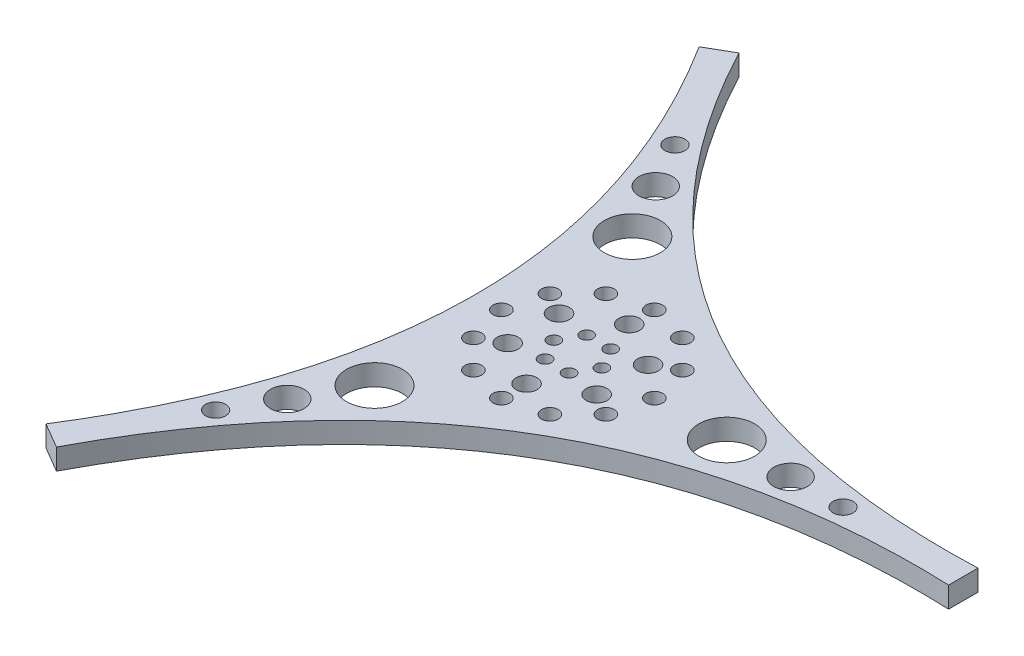
from build123d import *

# Parameters (mm, degrees)
SKETCH_1_R      = 2.392485623
SKETCH_1_R_2    = 4.007871621
SKETCH_1_R_3    = 6.678501703
SKETCH_1_R_4    = 1.5
SKETCH_1_R_5    = 2.5
SKETCH_1_R_6    = 2
EXTRUDE_4_DEPTH = 5


with BuildPart() as part:
    # Эскиз1 → Бобышка-Вытянуть4 (new body)
    with BuildSketch(Plane(origin=(0, 0, 0), x_dir=(1, 0, 0), z_dir=(0, 1, 0))):
        with BuildLine():
            Line((0, 163.036345265), (6.030702091, 166.518172741))
            add(Edge.make_bspline(
                [(6.030702091, 166.518172741), (49.074772944, 85.000000108), (141.146053562, 88.509288197)],
                knots=[0, 0, 0, 1, 1, 1], degree=2))
            Line((141.146053562, 88.509288197), (141.146053562, 81.490712019))
            add(Edge.make_bspline(
                [(6.030701589, 3.481827186), (49.074772944, 85.000000108), (141.146053562, 81.490712019)],
                knots=[0, 0, 0, 1, 1, 1], degree=2))
            Line((6.030701589, 3.481827186), (0, 7.029273997))
            add(Edge.make_bspline(
                [(0, 163.036345265), (49.074772944, 85.000000108), (0, 7.029273997)],
                knots=[0, 0, 0, 1, 1, 1], degree=2))
        make_face()
        with Locations((17.403131543, 139.856892173)):
            Circle(SKETCH_1_R, mode=Mode.SUBTRACT)
        with Locations((23.665499069, 129.010153442)):
            Circle(SKETCH_1_R_2, mode=Mode.SUBTRACT)
        with Locations((31.292672593, 115.79950138)):
            Circle(SKETCH_1_R_3, mode=Mode.SUBTRACT)
        with Locations((112.418055745, 85.000000108)):
            Circle(SKETCH_1_R, mode=Mode.SUBTRACT)
        with Locations((99.893320693, 85.000000108)):
            Circle(SKETCH_1_R_2, mode=Mode.SUBTRACT)
        with Locations((84.638973644, 85.000000108)):
            Circle(SKETCH_1_R_3, mode=Mode.SUBTRACT)
        with Locations((17.403131543, 30.143108043)):
            Circle(SKETCH_1_R, mode=Mode.SUBTRACT)
        with Locations((23.665499069, 40.989846774)):
            Circle(SKETCH_1_R_2, mode=Mode.SUBTRACT)
        with Locations((31.292672593, 54.200498836)):
            Circle(SKETCH_1_R_3, mode=Mode.SUBTRACT)
        with Locations((51.941543531, 80.034607797)):
            Circle(SKETCH_1_R_4, mode=Mode.SUBTRACT)
        with Locations((46.208002356, 80.034607797)):
            Circle(SKETCH_1_R_4, mode=Mode.SUBTRACT)
        with Locations((43.341231769, 85.000000108)):
            Circle(SKETCH_1_R_4, mode=Mode.SUBTRACT)
        with Locations((46.208002356, 89.965392419)):
            Circle(SKETCH_1_R_4, mode=Mode.SUBTRACT)
        with Locations((51.941543531, 89.965392419)):
            Circle(SKETCH_1_R_4, mode=Mode.SUBTRACT)
        with Locations((54.808314118, 85.000000108)):
            Circle(SKETCH_1_R_4, mode=Mode.SUBTRACT)
        with Locations((59.695284799, 91.142114645)):
            Circle(SKETCH_1_R_5, mode=Mode.SUBTRACT)
        with Locations((59.704256093, 78.873424309)):
            Circle(SKETCH_1_R_5, mode=Mode.SUBTRACT)
        with Locations((49.083744238, 72.731309772)):
            Circle(SKETCH_1_R_5, mode=Mode.SUBTRACT)
        with Locations((38.454261089, 78.857885572)):
            Circle(SKETCH_1_R_5, mode=Mode.SUBTRACT)
        with Locations((38.445289794, 91.126575908)):
            Circle(SKETCH_1_R_5, mode=Mode.SUBTRACT)
        with Locations((49.065801649, 97.268690444)):
            Circle(SKETCH_1_R_5, mode=Mode.SUBTRACT)
        with Locations((58.206663905, 100.816899223)):
            Circle(SKETCH_1_R_6, mode=Mode.SUBTRACT)
        with Locations((64.891672058, 94.13189107)):
            Circle(SKETCH_1_R_6, mode=Mode.SUBTRACT)
        with Locations((67.338554867, 85.000000108)):
            Circle(SKETCH_1_R_6, mode=Mode.SUBTRACT)
        with Locations((64.891672058, 75.868109147)):
            Circle(SKETCH_1_R_6, mode=Mode.SUBTRACT)
        with Locations((58.206663905, 69.183100994)):
            Circle(SKETCH_1_R_6, mode=Mode.SUBTRACT)
        with Locations((49.074772944, 66.736218185)):
            Circle(SKETCH_1_R_6, mode=Mode.SUBTRACT)
        with Locations((39.942881982, 69.183100994)):
            Circle(SKETCH_1_R_6, mode=Mode.SUBTRACT)
        with Locations((33.257873829, 75.868109147)):
            Circle(SKETCH_1_R_6, mode=Mode.SUBTRACT)
        with Locations((30.810991021, 85.000000108)):
            Circle(SKETCH_1_R_6, mode=Mode.SUBTRACT)
        with Locations((33.257873829, 94.13189107)):
            Circle(SKETCH_1_R_6, mode=Mode.SUBTRACT)
        with Locations((39.942881982, 100.816899223)):
            Circle(SKETCH_1_R_6, mode=Mode.SUBTRACT)
        with Locations((49.074772944, 103.263782031)):
            Circle(SKETCH_1_R_6, mode=Mode.SUBTRACT)
    extrude(amount=EXTRUDE_4_DEPTH)


solid = part.part
